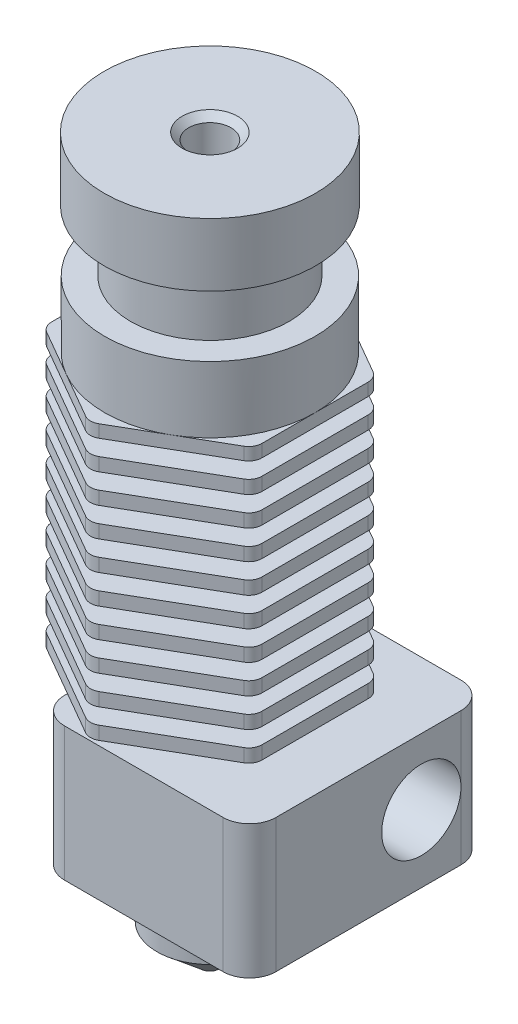
from build123d import *

# Parameters (mm, degrees)
BOSS_EXTRUDE1_DEPTH     = 25.75
SKETCH9_R               = 6
BOSS_EXTRUDE4_DEPTH     = 4.64
SKETCH10_R              = 8
BOSS_EXTRUDE5_DEPTH     = 4.76
SKETCH2_R               = 2
BOSS_EXTRUDE2_DEPTH     = 30
BOSS_EXTRUDE3_DEPTH     = 10.11
FILLET1_R               = 1
SKETCH5_R               = 4
NOZZLE_DEPTH            = 5
CHAMFER1_SIZE           = 2.8
CHAMFER1_SIZE2          = 3.336910059
CUT_EXTRUDE1_START      = -1
SKETCH6_R               = 2.75
CUT_EXTRUDE1_DEPTH      = 1.2
LPATTERN1_COUNT         = 9
LPATTERN1_PITCH         = 2.2
CUT_EXTRUDE2_DEPTH      = 5
SKETCH8_R               = 1.6
CUT_EXTRUDE3_DEPTH      = 9.4
CUT_EXTRUDE3_DEPTH_BACK = 43
CHAMFER2_SIZE           = 0.5
CUT_EXTRUDE4_REACH      = 18
SKETCH11_R              = 3


with BuildPart() as part:
    # Sketch1 → Boss-Extrude1 (new body)
    with BuildSketch(Plane(origin=(0, 0, 0), x_dir=(1, 0, 0), z_dir=(0, 1, 0))):
        Polygon((0, 9.19), (-7.958773461, 4.595), (-7.958773461, -4.595), (0, -9.19), (7.958773461, -4.595), (7.958773461, 4.595), align=None)
    extrude(amount=-BOSS_EXTRUDE1_DEPTH)

    # Sketch9 → Boss-Extrude4 (add)
    with BuildSketch(Plane(origin=(0, 0, 0), x_dir=(1, 0, 0), z_dir=(0, 1, 0))):
        Circle(SKETCH9_R)
    extrude(amount=BOSS_EXTRUDE4_DEPTH)

    # Sketch10 → Boss-Extrude5 (add)
    with BuildSketch(Plane(origin=(0, 4.64, 0), x_dir=(1, 0, 0), z_dir=(0, 1, 0))):
        Circle(SKETCH10_R)
    extrude(amount=BOSS_EXTRUDE5_DEPTH)

    # Sketch2 → Boss-Extrude2 (add)
    with BuildSketch(Plane(origin=(0, 0, 0), x_dir=(1, 0, 0), z_dir=(0, 1, 0))):
        Circle(SKETCH2_R)
    extrude(amount=-BOSS_EXTRUDE2_DEPTH)

    # Sketch4 → Boss-Extrude3 (add)
    with BuildSketch(Plane.XZ.offset(30)):
        with BuildLine():
            Line((-6, 5), (6, 5))
            ThreePointArc((6, 5), (7.414213562, 4.414213562), (8, 3))
            Line((8, 3), (8, -11))
            ThreePointArc((8, -11), (7.414213562, -12.414213562), (6, -13))
            Line((6, -13), (-6, -13))
            ThreePointArc((-6, -13), (-7.414213562, -12.414213562), (-8, -11))
            Line((-8, -11), (-8, 3))
            ThreePointArc((-8, 3), (-7.414213562, 4.414213562), (-6, 5))
        make_face()
    extrude(amount=BOSS_EXTRUDE3_DEPTH)

    # Fillet1
    fillet1_edges = [part.edges().sort_by_distance(p)[0] for p in [
        (7.958773461, -12.875, -4.595),
        (7.958773461, -12.875, 4.595),
        (0, -12.875, 9.19),
        (-7.958773461, -12.875, 4.595),
        (-7.958773461, -12.875, -4.595),
        (0, -12.875, -9.19),
    ]]
    fillet(fillet1_edges, radius=FILLET1_R)

    # Sketch5 → Nozzle (add)
    with BuildSketch(Plane.XZ.offset(40.11)):
        Circle(SKETCH5_R)
    extrude(amount=NOZZLE_DEPTH)

    # Chamfer1
    chamfer1_edges = [part.edges().sort_by_distance(p)[0] for p in [
        (-4, -45.11, 0),
    ]]
    chamfer1_side = [part.faces().sort_by_distance(p)[0] for p in [
        (-4, -42.61, 0),
    ]]
    chamfer(chamfer1_edges, length=CHAMFER1_SIZE, length2=CHAMFER1_SIZE2, reference=chamfer1_side[0])

    # Sketch6 → Cut-Extrude1 (cut)
    with BuildSketch(Plane.XZ.offset(25.75).offset(CUT_EXTRUDE1_START)):
        with BuildLine():
            Line((0.5, -8.901324865), (7.458773461, -4.883675135))
            ThreePointArc((7.458773461, -4.883675135), (7.824798865, -4.517649731), (7.958773461, -4.017649731))
            Line((7.958773461, -4.017649731), (7.958773461, 4.017649731))
            ThreePointArc((7.958773461, 4.017649731), (7.824798865, 4.517649731), (7.458773461, 4.883675135))
            Line((7.458773461, 4.883675135), (0.5, 8.901324865))
            ThreePointArc((0.5, 8.901324865), (0, 9.035299462), (-0.5, 8.901324865))
            Line((-0.5, 8.901324865), (-7.458773461, 4.883675135))
            ThreePointArc((-7.458773461, 4.883675135), (-7.824798865, 4.517649731), (-7.958773461, 4.017649731))
            Line((-7.958773461, 4.017649731), (-7.958773461, -4.017649731))
            ThreePointArc((-7.958773461, -4.017649731), (-7.824798865, -4.517649731), (-7.458773461, -4.883675135))
            Line((-7.458773461, -4.883675135), (-0.5, -8.901324865))
            ThreePointArc((-0.5, -8.901324865), (0, -9.035299462), (0.5, -8.901324865))
        make_face()
        Circle(SKETCH6_R, mode=Mode.SUBTRACT)
    cut_extrude1 = extrude(amount=-CUT_EXTRUDE1_DEPTH, mode=Mode.SUBTRACT)

    # LPattern1: Cut-Extrude1 ×9
    with Locations(*[(0, i * LPATTERN1_PITCH, 0) for i in range(1, LPATTERN1_COUNT)]):
        add(cut_extrude1, mode=Mode.SUBTRACT)

    # Sketch7 → Cut-Extrude2 (cut)
    with BuildSketch(Plane(origin=(0, 0, 0), x_dir=(1, 0, 0), z_dir=(0, 1, 0))):
        with BuildLine():
            Line((-7.458773461, -4.883675135), (-3.979386882, -6.892499913))
            ThreePointArc((-3.979386882, -6.892499913), (-6.892500044, -3.979386655), (-7.958773461, 0))
            Line((-7.958773461, 0), (-7.958773461, -4.017649731))
            ThreePointArc((-7.958773461, -4.017649731), (-7.824798865, -4.517649731), (-7.458773461, -4.883675135))
        make_face()
        with BuildLine():
            ThreePointArc((-7.958773461, 0), (-6.892499992, 3.979386744), (-3.979386704, 6.892500015))
            Line((-3.979386704, 6.892500015), (-7.458773461, 4.883675135))
            ThreePointArc((-7.458773461, 4.883675135), (-7.824798865, 4.517649731), (-7.958773461, 4.017649731))
            Line((-7.958773461, 4.017649731), (-7.958773461, 0))
        make_face()
        with BuildLine():
            ThreePointArc((-3.979386704, 6.892500015), (-2.2e-08, 7.958773461), (3.979386666, 6.892500037))
            Line((3.979386666, 6.892500037), (0.5, 8.901324865))
            ThreePointArc((0.5, 8.901324865), (0, 9.035299462), (-0.5, 8.901324865))
            Line((-0.5, 8.901324865), (-3.979386704, 6.892500015))
        make_face()
        with BuildLine():
            ThreePointArc((3.979386666, 6.892500037), (6.892499981, 3.979386763), (7.958773461, 0))
            Line((7.958773461, 0), (7.958773461, 4.017649731))
            ThreePointArc((7.958773461, 4.017649731), (7.824798865, 4.517649731), (7.458773461, 4.883675135))
            Line((7.458773461, 4.883675135), (3.979386666, 6.892500037))
        make_face()
        with BuildLine():
            ThreePointArc((7.458773461, -4.883675135), (7.824798865, -4.517649731), (7.958773461, -4.017649731))
            Line((7.958773461, -4.017649731), (7.958773461, 0))
            ThreePointArc((7.958773461, 0), (6.892500042, -3.979386657), (3.979386877, -6.892499915))
            Line((3.979386877, -6.892499915), (7.458773461, -4.883675135))
        make_face()
        with BuildLine():
            Line((0.5, -8.901324865), (3.979386877, -6.892499915))
            ThreePointArc((3.979386877, -6.892499915), (-3e-09, -7.958773461), (-3.979386882, -6.892499913))
            Line((-3.979386882, -6.892499913), (-0.5, -8.901324865))
            ThreePointArc((-0.5, -8.901324865), (0, -9.035299462), (0.5, -8.901324865))
        make_face()
    extrude(amount=-CUT_EXTRUDE2_DEPTH, mode=Mode.SUBTRACT)

    # Sketch8 → Cut-Extrude3 (cut, two sides)
    with BuildSketch(Plane(origin=(0, 0, 0), x_dir=(1, 0, 0), z_dir=(0, 1, 0))) as cut_extrude3_sk:
        Circle(SKETCH8_R)
    extrude(amount=CUT_EXTRUDE3_DEPTH, mode=Mode.SUBTRACT)
    extrude(cut_extrude3_sk.sketch, amount=-CUT_EXTRUDE3_DEPTH_BACK, mode=Mode.SUBTRACT)

    # Chamfer2
    chamfer2_edges = [part.edges().sort_by_distance(p)[0] for p in [
        (-1.6, 9.4, 0),
    ]]
    chamfer(chamfer2_edges, length=CHAMFER2_SIZE)

    # Sketch11 → Cut-Extrude4 (cut, up to next)
    with BuildSketch(Plane.ZY.offset(8), mode=Mode.PRIVATE) as cut_extrude4_sk1:
        with Locations((-8, -35)):
            Circle(SKETCH11_R)
    cut_extrude4_tool1 = extrude(cut_extrude4_sk1.sketch, amount=-CUT_EXTRUDE4_REACH, mode=Mode.PRIVATE) & part.part
    add(cut_extrude4_tool1.solids().sort_by_distance((-8, -35, -8))[0], mode=Mode.SUBTRACT)


solid = part.part
